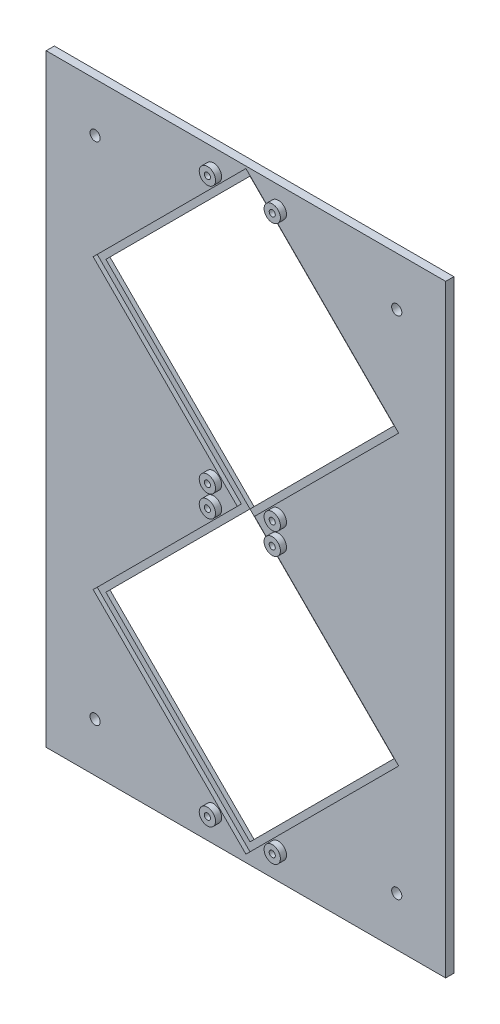
from build123d import *

# Parameters (mm, degrees)
ESQUISSE1_W                          = 194
ESQUISSE1_H                          = 294
BOSS_EXTRU_1_DEPTH                   = 4
ESQUISSE2_R                          = 2.5
ENL_V_MAT_EXTRU_4_DEPTH              = 330.683341579
ENL_V_MAT_EXTRU_17_DEPTH             = 330.683341579
R_P_TITION_LIN_AIRE2_COUNT           = 2
R_P_TITION_LIN_AIRE2_PITCH           = 141.43
ESQUISSE5_R                          = 4
BOSS_EXTRU_2_DEPTH                   = 3
ESQUISSE6_R                          = 1.5
ENL_V_MAT_EXTRU_18_DEPTH             = 6
ESQUISSE7_R                          = 1.5
ENL_V_MAT_EXTRU_19_DEPTH             = 6
R_P_TITION_LIN_AIRE5_COUNT           = 2
R_P_TITION_LIN_AIRE5_PITCH           = 130.815
ESQUISSE10_R                         = 1.5
ENL_V_MAT_EXTRU_20_DEPTH             = 6
ESQUISSE9_R                          = 4
BOSS_EXTRU_3_DEPTH                   = 3
ESQUISSE11_R                         = 1.5
ENL_V_MAT_EXTRU_21_DEPTH             = 6
R_P_TITION_LIN_AIRE6_COUNT           = 2
R_P_TITION_LIN_AIRE6_PITCH           = 31.82
R_P_TITION_LIN_AIRE7_COPY_1_SKETCH_R = 4
R_P_TITION_LIN_AIRE7_COPY_1_DEPTH    = 3
R_P_TITION_LIN_AIRE7_COPY_2_SKETCH_R = 1.5
R_P_TITION_LIN_AIRE7_COPY_2_DEPTH    = 6
R_P_TITION_LIN_AIRE7_COPY_3_SKETCH_R = 4
R_P_TITION_LIN_AIRE7_COPY_3_DEPTH    = 3
R_P_TITION_LIN_AIRE7_COPY_4_SKETCH_R = 1.5
R_P_TITION_LIN_AIRE7_COPY_4_DEPTH    = 6
ENL_V_MAT_EXTRU_22_DEPTH             = 2
ENL_V_MAT_EXTRU_23_DEPTH             = 2
ENL_V_MAT_EXTRU_25_DEPTH             = 2
ENL_V_MAT_EXTRU_27_DEPTH             = 2
ENL_V_MAT_EXTRU_28_DEPTH             = 2
ENL_V_MAT_EXTRU_29_DEPTH             = 2
ENL_V_MAT_EXTRU_30_DEPTH             = 2
ENL_V_MAT_EXTRU_31_DEPTH             = 2
ESQUISSE23_W                         = 4
ESQUISSE23_H                         = 294
BOSS_EXTRU_4_DEPTH                   = 1
R_P_TITION_LIN_AIRE8_COUNT           = 2
R_P_TITION_LIN_AIRE8_PITCH           = 195
ESQUISSE24_W                         = 196
ESQUISSE24_H                         = 4
BOSS_EXTRU_5_DEPTH                   = 1
R_P_TITION_LIN_AIRE9_COUNT           = 2
R_P_TITION_LIN_AIRE9_PITCH           = 295


with BuildPart() as part:
    # Esquisse1 → Boss.-Extru.1 (new body)
    with BuildSketch(Plane.XY):
        with Locations((76.321557543, 133.418871343)):
            Rectangle(ESQUISSE1_W, ESQUISSE1_H)
    extrude(amount=BOSS_EXTRU_1_DEPTH)

    # Esquisse2 → Enlèv. mat.-Extru.4 (cut, through all)
    with BuildSketch(Plane.XY):
        with Locations((2.321557543, 257.418871343)):
            Circle(ESQUISSE2_R)
        with Locations((150.321557543, 257.418871343)):
            Circle(ESQUISSE2_R)
        with Locations((150.321557543, 9.418871343)):
            Circle(ESQUISSE2_R)
        with Locations((2.321557543, 9.418871343)):
            Circle(ESQUISSE2_R)
    extrude(amount=ENL_V_MAT_EXTRU_4_DEPTH, mode=Mode.SUBTRACT)

    # Esquisse4 → Enlèv. mat.-Extru.17 (cut, through all)
    with BuildSketch(Plane.XY.offset(4)):
        Polygon((147.032235662, 205.408193225), (76.321557543, 276.118871343), (5.610879425, 205.408193225), (76.321557543, 134.697515106), align=None)
    enl_v_mat_extru_17 = extrude(amount=-ENL_V_MAT_EXTRU_17_DEPTH, mode=Mode.SUBTRACT)

    # Répétition linéaire2: Enlèv. mat.-Extru.17 ×2
    with Locations(*[(0, -i * R_P_TITION_LIN_AIRE2_PITCH, 0) for i in range(1, R_P_TITION_LIN_AIRE2_COUNT)]):
        add(enl_v_mat_extru_17, mode=Mode.SUBTRACT)

    # Esquisse5 → Boss.-Extru.2 (add)
    with BuildSketch(Plane.XY.offset(4)):
        with Locations((60.411654967, 270.815570484)):
            Circle(ESQUISSE5_R)
        with Locations((92.23146012, 270.815570484)):
            Circle(ESQUISSE5_R)
    boss_extru_2 = extrude(amount=BOSS_EXTRU_2_DEPTH)

    # Esquisse6 → Enlèv. mat.-Extru.18 (cut)
    with BuildSketch(Plane.XY.offset(7)):
        with Locations((60.411654967, 270.815570484)):
            Circle(ESQUISSE6_R)
    enl_v_mat_extru_18 = extrude(amount=-ENL_V_MAT_EXTRU_18_DEPTH, mode=Mode.SUBTRACT)

    # Esquisse7 → Enlèv. mat.-Extru.19 (cut)
    with BuildSketch(Plane.XY.offset(7)):
        with Locations((92.23146012, 270.815570484)):
            Circle(ESQUISSE7_R)
    extrude(amount=-ENL_V_MAT_EXTRU_19_DEPTH, mode=Mode.SUBTRACT)

    # Répétition linéaire5: Boss.-Extru.2, Enlèv. mat.-Extru.18 ×2
    with Locations(*[(0, -i * R_P_TITION_LIN_AIRE5_PITCH, 0) for i in range(1, R_P_TITION_LIN_AIRE5_COUNT)]):
        add(boss_extru_2)
        add(enl_v_mat_extru_18, mode=Mode.SUBTRACT)

    # Esquisse10 → Enlèv. mat.-Extru.20 (cut)
    with BuildSketch(Plane.XY.offset(7)):
        with Locations((92.23146012, 140.000570484)):
            Circle(ESQUISSE10_R)
    extrude(amount=-ENL_V_MAT_EXTRU_20_DEPTH, mode=Mode.SUBTRACT)

    # Esquisse9 → Boss.-Extru.3 (add)
    with BuildSketch(Plane.XY.offset(4)):
        with Locations((92.23146012, 129.385570484)):
            Circle(ESQUISSE9_R)
    boss_extru_3 = extrude(amount=BOSS_EXTRU_3_DEPTH)

    # Esquisse11 → Enlèv. mat.-Extru.21 (cut)
    with BuildSketch(Plane.XY.offset(7)):
        with Locations((92.23146012, 129.385570484)):
            Circle(ESQUISSE11_R)
    enl_v_mat_extru_21 = extrude(amount=-ENL_V_MAT_EXTRU_21_DEPTH, mode=Mode.SUBTRACT)

    # Répétition linéaire6: Boss.-Extru.3, Enlèv. mat.-Extru.21 ×2
    with Locations(*[(-i * R_P_TITION_LIN_AIRE6_PITCH, 0, 0) for i in range(1, R_P_TITION_LIN_AIRE6_COUNT)]):
        add(boss_extru_3)
        add(enl_v_mat_extru_21, mode=Mode.SUBTRACT)

    # Répétition linéaire7 copy 1 sketch → Répétition linéaire7 copy 1 (add)
    with BuildSketch(Plane(origin=(-31.82, -130.815, 4), x_dir=(1, 0, 0), z_dir=(0, 0, 1))):
        with Locations((92.23146012, 129.385570484)):
            Circle(R_P_TITION_LIN_AIRE7_COPY_1_SKETCH_R)
    extrude(amount=R_P_TITION_LIN_AIRE7_COPY_1_DEPTH)

    # Répétition linéaire7 copy 2 sketch → Répétition linéaire7 copy 2 (cut)
    with BuildSketch(Plane(origin=(-31.82, -130.815, 7), x_dir=(1, 0, 0), z_dir=(0, 0, 1))):
        with Locations((92.23146012, 129.385570484)):
            Circle(R_P_TITION_LIN_AIRE7_COPY_2_SKETCH_R)
    extrude(amount=-R_P_TITION_LIN_AIRE7_COPY_2_DEPTH, mode=Mode.SUBTRACT)

    # Répétition linéaire7 copy 3 sketch → Répétition linéaire7 copy 3 (add)
    with BuildSketch(Plane(origin=(0, -130.815, 4), x_dir=(1, 0, 0), z_dir=(0, 0, 1))):
        with Locations((92.23146012, 129.385570484)):
            Circle(R_P_TITION_LIN_AIRE7_COPY_3_SKETCH_R)
    extrude(amount=R_P_TITION_LIN_AIRE7_COPY_3_DEPTH)

    # Répétition linéaire7 copy 4 sketch → Répétition linéaire7 copy 4 (cut)
    with BuildSketch(Plane(origin=(0, -130.815, 7), x_dir=(1, 0, 0), z_dir=(0, 0, 1))):
        with Locations((92.23146012, 129.385570484)):
            Circle(R_P_TITION_LIN_AIRE7_COPY_4_SKETCH_R)
    extrude(amount=-R_P_TITION_LIN_AIRE7_COPY_4_DEPTH, mode=Mode.SUBTRACT)

    # Esquisse13 → Enlèv. mat.-Extru.22 (cut)
    with BuildSketch(Plane.XY.offset(4)):
        Polygon((76.321557543, 276.118871343), (147.032235662, 205.408193225), (149.153556006, 207.529513568), (78.442877887, 278.240191687), align=None)
    extrude(amount=-ENL_V_MAT_EXTRU_22_DEPTH, mode=Mode.SUBTRACT)

    # Esquisse14 → Enlèv. mat.-Extru.23 (cut)
    with BuildSketch(Plane.XY.offset(4)):
        Polygon((5.610879425, 205.408193225), (78.442877887, 278.240191687), (76.321557543, 280.36151203), (3.489559081, 207.529513568), align=None)
    extrude(amount=-ENL_V_MAT_EXTRU_23_DEPTH, mode=Mode.SUBTRACT)

    # Esquisse15 → Enlèv. mat.-Extru.25 (cut)
    with BuildSketch(Plane.XY.offset(4)):
        Polygon((76.325879425, 134.693193225), (3.489559081, 207.529513568), (1.368238738, 205.408193225), (74.204559081, 132.571872881), align=None)
    extrude(amount=-ENL_V_MAT_EXTRU_25_DEPTH, mode=Mode.SUBTRACT)

    # Esquisse16 → Enlèv. mat.-Extru.27 (cut)
    with BuildSketch(Plane.XY.offset(4)):
        Polygon((76.317235662, 134.693193225), (149.153556006, 207.529513568), (151.274876349, 205.408193225), (78.438556006, 132.571872881), align=None)
    extrude(amount=-ENL_V_MAT_EXTRU_27_DEPTH, mode=Mode.SUBTRACT)

    # Esquisse19 → Enlèv. mat.-Extru.28 (cut)
    with BuildSketch(Plane.XY.offset(4)):
        Polygon((74.204559081, 132.571872881), (5.610879425, 63.978193225), (3.489559081, 66.099513568), (72.083238738, 134.693193225), align=None)
    extrude(amount=-ENL_V_MAT_EXTRU_28_DEPTH, mode=Mode.SUBTRACT)

    # Esquisse20 → Enlèv. mat.-Extru.29 (cut)
    with BuildSketch(Plane.XY.offset(4)):
        Polygon((3.489559081, 66.099513568), (76.321557543, -6.732484894), (74.2002372, -8.853805238), (1.368238738, 63.978193225), align=None)
    extrude(amount=-ENL_V_MAT_EXTRU_29_DEPTH, mode=Mode.SUBTRACT)

    # Esquisse21 → Enlèv. mat.-Extru.30 (cut)
    with BuildSketch(Plane.XY.offset(4)):
        Polygon((74.2002372, -8.853805238), (147.032235662, 63.978193225), (149.153556006, 61.856872881), (76.321557543, -10.975125581), align=None)
    extrude(amount=-ENL_V_MAT_EXTRU_30_DEPTH, mode=Mode.SUBTRACT)

    # Esquisse22 → Enlèv. mat.-Extru.31 (cut)
    with BuildSketch(Plane.XY.offset(4)):
        Polygon((149.153556006, 61.856872881), (78.438556006, 132.571872881), (80.559876349, 134.693193225), (151.274876349, 63.978193225), align=None)
    extrude(amount=-ENL_V_MAT_EXTRU_31_DEPTH, mode=Mode.SUBTRACT)

    # Esquisse23 → Boss.-Extru.4 (add)
    with BuildSketch(Plane(origin=(173.321557543, 0, 0), x_dir=(0, 0, -1), z_dir=(1, 0, 0))):
        with Locations((-2, 133.418871343)):
            Rectangle(ESQUISSE23_W, ESQUISSE23_H)
    boss_extru_4 = extrude(amount=BOSS_EXTRU_4_DEPTH)

    # Répétition linéaire8: Boss.-Extru.4 ×2
    with Locations(*[(-i * R_P_TITION_LIN_AIRE8_PITCH, 0, 0) for i in range(1, R_P_TITION_LIN_AIRE8_COUNT)]):
        add(boss_extru_4)

    # Esquisse24 → Boss.-Extru.5 (add)
    with BuildSketch(Plane(origin=(0, 280.418871343, 0), x_dir=(1, 0, 0), z_dir=(0, 1, 0))):
        with Locations((76.321557543, -2)):
            Rectangle(ESQUISSE24_W, ESQUISSE24_H)
    boss_extru_5 = extrude(amount=BOSS_EXTRU_5_DEPTH)

    # Répétition linéaire9: Boss.-Extru.5 ×2
    with Locations(*[(0, -i * R_P_TITION_LIN_AIRE9_PITCH, 0) for i in range(1, R_P_TITION_LIN_AIRE9_COUNT)]):
        add(boss_extru_5)


solid = part.part
